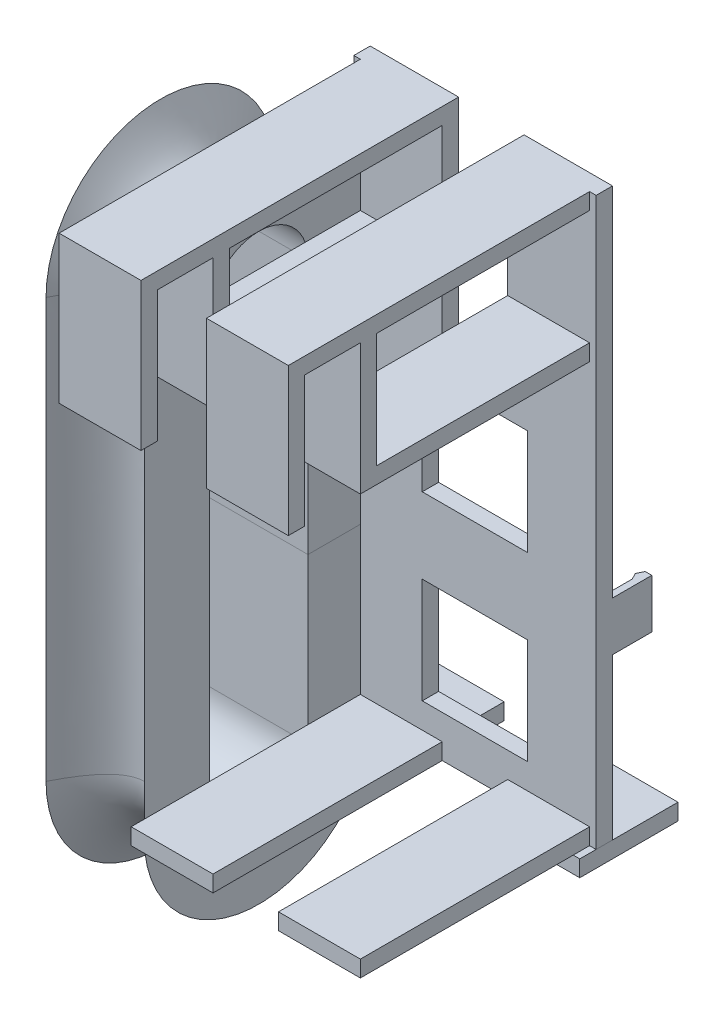
from build123d import *

# Parameters (mm, degrees)
SKETCH1_W                  = 25
SKETCH1_H                  = 60
SKETCH1_W_2                = 70
SKETCH1_H_2                = 113
SKETCH1_W_3                = 32.2
SKETCH1_H_3                = 32.2
BOSS_EXTRUDE1_DEPTH        = 5
SKETCH2_W                  = 65
SKETCH2_H                  = 5
SKETCH2_W_2                = 5
SKETCH2_H_2                = 40
SKETCH2_W_3                = 92
SKETCH2_W_4                = 70
BOSS_EXTRUDE2_DEPTH        = 25
SKETCH3_W                  = 12
SKETCH3_H                  = 15
BOSS_EXTRUDE3_DEPTH        = 2
BOSS_EXTRUDE5_DEPTH        = 15
SKETCH5_W                  = 20.9
SKETCH5_H                  = 5
BOSS_EXTRUDE6_DEPTH        = 20
BOSS_EXTRUDE6_DEPTH_BACK   = 10
BOSS_EXTRUDE6_2_DEPTH      = 20
BOSS_EXTRUDE6_2_DEPTH_BACK = 10
FILLET1_R                  = 2


with BuildPart() as part:
    # Sketch1 → Boss-Extrude1 (new body)
    with BuildSketch(Plane.XY):
        with Locations((12.5, 143)):
            Rectangle(SKETCH1_W, SKETCH1_H)
        with Locations((57.5, 143)):
            Rectangle(SKETCH1_W, SKETCH1_H)
        with Locations((35, 56.5)):
            Rectangle(SKETCH1_W_2, SKETCH1_H_2)
        with Locations((35, 28.85)):
            Rectangle(SKETCH1_W_3, SKETCH1_H_3, mode=Mode.SUBTRACT)
        with Locations((35, 84.15)):
            Rectangle(SKETCH1_W_3, SKETCH1_H_3, mode=Mode.SUBTRACT)
        Polygon((0, 173), (-2, 173), (-2, 0), (0, 0), (0, 113), align=None)
        Polygon((70, 0), (72, 0), (72, 173), (70, 173), (70, 113), align=None)
    extrude(amount=BOSS_EXTRUDE1_DEPTH)

    # Sketch2 → Boss-Extrude2 (add)
    with BuildSketch(Plane(origin=(0, 0, 0), x_dir=(0, 0, -1), z_dir=(1, 0, 0))):
        with Locations((-37.5, 130.5)):
            Rectangle(SKETCH2_W, SKETCH2_H)
        Polygon((-70, 133), (-70, 168), (-75, 168), (-75, 128), (-70, 128), align=None)
        with Locations((-94.5, 148)):
            Rectangle(SKETCH2_W_2, SKETCH2_H_2)
        with Locations((-51, 170.5)):
            Rectangle(SKETCH2_W_3, SKETCH2_H)
        with Locations((-40, 2.5)):
            Rectangle(SKETCH2_W_4, SKETCH2_H)
    boss_extrude2 = extrude(amount=BOSS_EXTRUDE2_DEPTH)

    # Mirror2: Boss-Extrude2 across plane
    add(boss_extrude2.mirror(Plane(origin=(35, 0, 0), x_dir=(0, 0, 1), z_dir=(1, 0, 0))))

    # Sketch3 → Boss-Extrude3 (add, through all)
    with BuildSketch(Plane(origin=(0, 0, 0), x_dir=(0, 0, -1), z_dir=(1, 0, 0))):
        with Locations((6, 56.5)):
            Rectangle(SKETCH3_W, SKETCH3_H)
    boss_extrude3 = extrude(amount=-BOSS_EXTRUDE3_DEPTH)

    # Sketch4 → Boss-Extrude5 (add)
    with BuildSketch(Plane(origin=(0, 64, 0), x_dir=(1, 0, 0), z_dir=(0, 1, 0))):
        Polygon((1, 10), (0, 12), (0, 10), align=None)
        Polygon((0, 8), (1, 10), (0, 10), align=None)
    boss_extrude5 = extrude(amount=-BOSS_EXTRUDE5_DEPTH)

    # Mirror3: Boss-Extrude3, Boss-Extrude5 across plane
    add(boss_extrude3.mirror(Plane(origin=(35, 0, 0), x_dir=(0, 0, 1), z_dir=(1, 0, 0))))
    add(boss_extrude5.mirror(Plane(origin=(35, 0, 0), x_dir=(0, 0, 1), z_dir=(1, 0, 0))))

    # Fillet1
    fillet1_edges = [part.edges().sort_by_distance(p)[0] for p in [
        (0, 56.5, 0),
        (70, 56.5, 0),
    ]]
    fillet(fillet1_edges, radius=FILLET1_R)



with BuildPart() as body_2:
    # Sketch5 → Boss-Extrude6 (new body, two sides)
    with BuildSketch(Plane(origin=(0, 0, 0), x_dir=(-1, 0, 0), z_dir=(0, 0, -1))) as boss_extrude6_sk:
        with Locations((-61.55, -2.5)):
            Rectangle(SKETCH5_W, SKETCH5_H)
    extrude(amount=BOSS_EXTRUDE6_DEPTH)
    extrude(boss_extrude6_sk.sketch, amount=-BOSS_EXTRUDE6_DEPTH_BACK)


with BuildPart() as body_3:
    # Sketch5 → Boss-Extrude6 2 (new body, two sides)
    with BuildSketch(Plane(origin=(0, 0, 0), x_dir=(-1, 0, 0), z_dir=(0, 0, -1))) as boss_extrude6_2_sk:
        with Locations((-8.45, -2.5)):
            Rectangle(SKETCH5_W, SKETCH5_H)
    extrude(amount=BOSS_EXTRUDE6_2_DEPTH)
    extrude(boss_extrude6_2_sk.sketch, amount=-BOSS_EXTRUDE6_2_DEPTH_BACK)


with BuildPart() as part_1:
    add(part.part)

    add(body_3.part)  # Sweep5 merges body 3
    # Sweep5: sweep along a path in Sketch7
    with BuildLine(Plane.ZY) as sweep5_path:
        Line((51, 128), (51, 0))
        ThreePointArc((51, 0), (36, -15), (21, 0))
        Line((21, 0), (21, 128))
        ThreePointArc((21, 128), (36, 143), (51, 128))
    # Sketch8 → Sweep5 (sweep)
    with BuildSketch(Plane(origin=(0, 50, 0), x_dir=(1, 0, 0), z_dir=(0, 1, 0))):
        with BuildLine():
            Line((0, -21), (-30, -21))
            Line((-30, -21), (-30, -1))
            add(Edge.make_bspline(
                [(-30, -1), (-15, -31), (0, -1)],
                knots=[0, 0, 0, 1, 1, 1], degree=2))
            Line((0, -1), (0, -21))
        make_face()
    sweep(path=sweep5_path.line)


solid = Compound([body_2.part, part_1.part])
